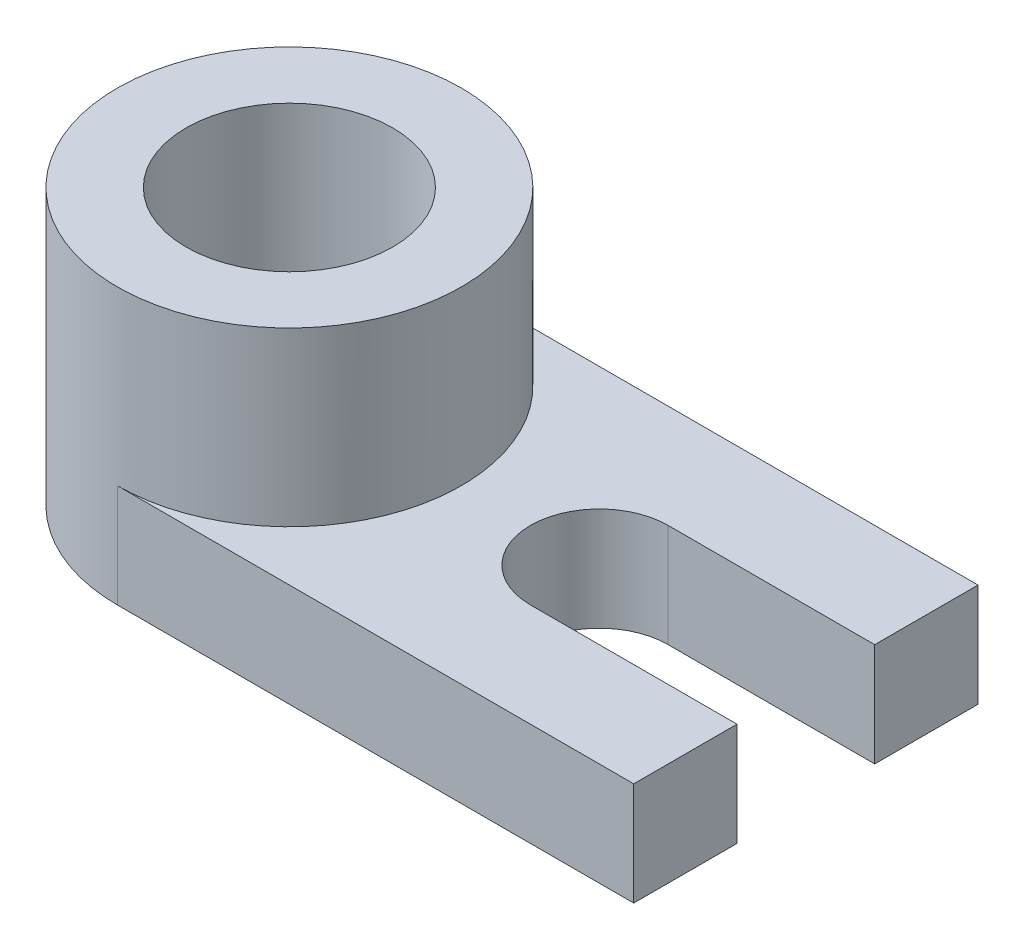
from build123d import *

# Parameters (mm, degrees)
SKETCH1_W           = 75
SKETCH1_H           = 50
BOSS_EXTRUDE1_DEPTH = 15
SKETCH2_R           = 25
BOSS_EXTRUDE2_DEPTH = 40
SKETCH3_R           = 15
CUT_EXTRUDE1_DEPTH  = 41
SKETCH4_R           = 10
CUT_EXTRUDE2_DEPTH  = 16
CUT_EXTRUDE3_REACH  = 102
SKETCH5_W           = 20
SKETCH5_H           = 15


with BuildPart() as part:
    # Sketch1 → Boss-Extrude1 (new body)
    with BuildSketch(Plane(origin=(0, 0, 0), x_dir=(1, 0, 0), z_dir=(0, 1, 0))):
        with Locations((37.5, 25)):
            Rectangle(SKETCH1_W, SKETCH1_H)
    extrude(amount=BOSS_EXTRUDE1_DEPTH)

    # Sketch2 → Boss-Extrude2 (add)
    with BuildSketch(Plane.XZ):
        with Locations((0, -25)):
            Circle(SKETCH2_R)
    extrude(amount=-BOSS_EXTRUDE2_DEPTH)

    # Sketch3 → Cut-Extrude1 (cut, through all)
    with BuildSketch(Plane(origin=(0, 40, 0), x_dir=(1, 0, 0), z_dir=(0, 1, 0))):
        with Locations((0, 25)):
            Circle(SKETCH3_R)
    extrude(amount=-CUT_EXTRUDE1_DEPTH, mode=Mode.SUBTRACT)

    # Sketch4 → Cut-Extrude2 (cut, through all)
    with BuildSketch(Plane(origin=(0, 15, 0), x_dir=(1, 0, 0), z_dir=(0, 1, 0))):
        with Locations((45, 25)):
            Circle(SKETCH4_R)
    extrude(amount=-CUT_EXTRUDE2_DEPTH, mode=Mode.SUBTRACT)

    # Sketch5 → Cut-Extrude3 (cut, up to next)
    with BuildSketch(Plane(origin=(75, 0, 0), x_dir=(0, 0, -1), z_dir=(1, 0, 0)), mode=Mode.PRIVATE) as cut_extrude3_sk1:
        with Locations((25, 7.5)):
            Rectangle(SKETCH5_W, SKETCH5_H)
    cut_extrude3_tool1 = extrude(cut_extrude3_sk1.sketch, amount=-CUT_EXTRUDE3_REACH, mode=Mode.PRIVATE) & part.part
    add(cut_extrude3_tool1.solids().sort_by_distance((75, 7.5, -25))[0], mode=Mode.SUBTRACT)


solid = part.part
